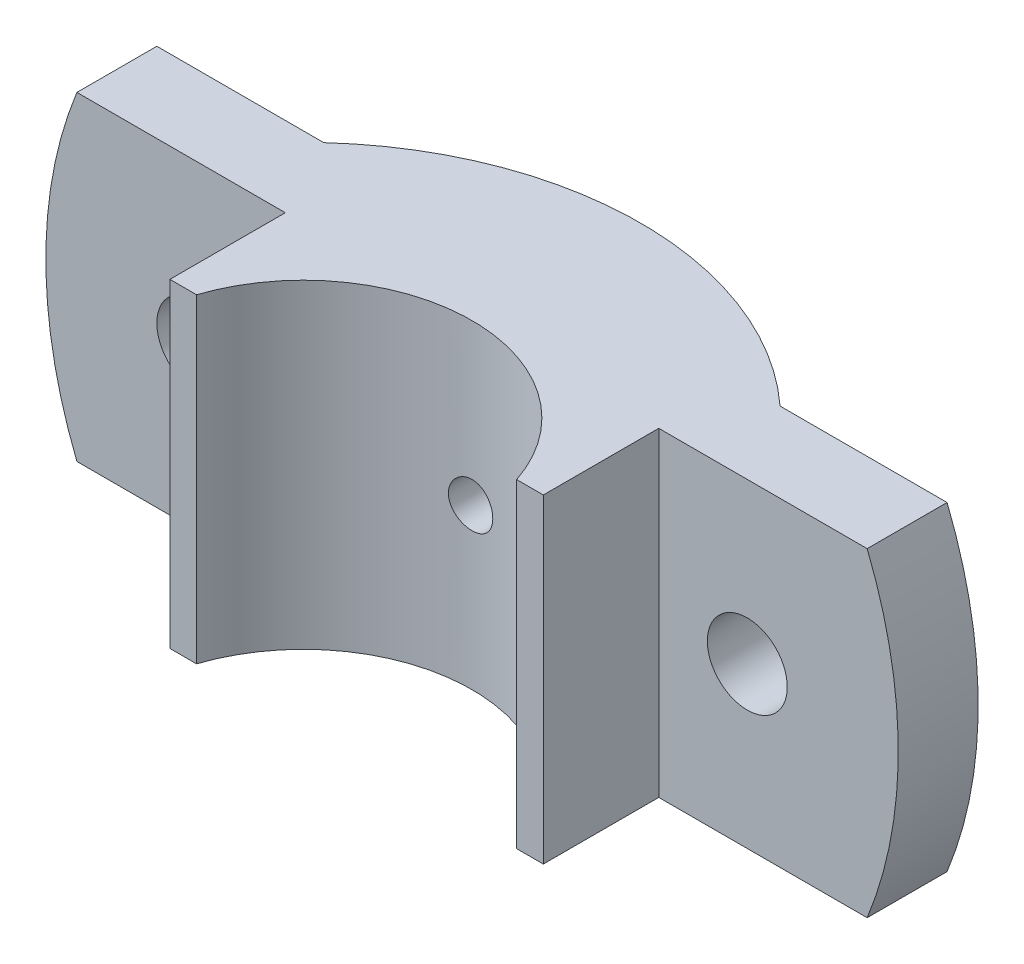
from build123d import *

# Parameters (mm, degrees)
BOSS_EXTRUDE1_DEPTH = 18
CUT_EXTRUDE1_DEPTH  = 36
SKETCH7_R           = 4.5
CUT_EXTRUDE3_DEPTH  = 36
CUT_EXTRUDE4_DEPTH  = 11


with BuildPart() as part:
    # Sketch2 → Boss-Extrude1 (new body, symmetric)
    with BuildSketch(Plane(origin=(0, 0, 0), x_dir=(1, 0, 0), z_dir=(0, 1, 0))):
        with BuildLine():
            Line((-25.690465157, 28), (-50, 28))
            Line((-50, 28), (-50, 19))
            Line((-50, 19), (-21.027756377, 19))
            Line((-21.027756377, 19), (-21.027756377, 6))
            Line((-21.027756377, 6), (-18.027756377, 6))
            ThreePointArc((-18.027756377, 6), (0, 19), (18.027756377, 6))
            Line((18.027756377, 6), (21.027756377, 6))
            Line((21.027756377, 6), (21.027756377, 19))
            Line((21.027756377, 19), (50, 19))
            Line((50, 19), (50, 28))
            Line((50, 28), (25.690465157, 28))
            ThreePointArc((25.690465157, 28), (0, 38), (-25.690465157, 28))
        make_face()
    extrude(amount=BOSS_EXTRUDE1_DEPTH, both=True)

    # Sketch4 → Cut-Extrude1 (cut)
    with BuildSketch(Plane(origin=(0, 0, -28), x_dir=(-1, 0, 0), z_dir=(0, 0, -1))):
        with BuildLine():
            Line((-50, -18), (-44.497190923, -18))
            ThreePointArc((-44.497190923, -18), (-48, 0), (-44.497190923, 18))
            Line((-44.497190923, 18), (-50, 18))
            Line((-50, 18), (-50, -18))
        make_face()
    cut_extrude1 = extrude(amount=-CUT_EXTRUDE1_DEPTH, mode=Mode.SUBTRACT)

    # Mirror1: Cut-Extrude1 across plane
    add(cut_extrude1.mirror(Plane(origin=(0, 0, 0), x_dir=(0, 0, 1), z_dir=(1, 0, 0))), mode=Mode.SUBTRACT)

    # Sketch7 → Cut-Extrude3 (cut)
    with BuildSketch(Plane(origin=(0, 0, -28), x_dir=(-1, 0, 0), z_dir=(0, 0, -1))):
        with Locations((-31, 0)):
            Circle(SKETCH7_R)
    cut_extrude3 = extrude(amount=-CUT_EXTRUDE3_DEPTH, mode=Mode.SUBTRACT)

    # Sketch8 → Cut-Extrude4 (cut, through all)
    with BuildSketch(Plane(origin=(0, 0, -28), x_dir=(-1, 0, 0), z_dir=(0, 0, -1))):
        with BuildLine():
            Line((-25.690465157, 6.637683312), (-25.690465157, -6.637683312))
            ThreePointArc((-25.690465157, -6.637683312), (-22.5, 0), (-25.690465157, 6.637683312))
        make_face()
    cut_extrude4 = extrude(amount=CUT_EXTRUDE4_DEPTH, mode=Mode.SUBTRACT)

    # Mirror3: Cut-Extrude3, Cut-Extrude4 across plane
    add(cut_extrude3.mirror(Plane(origin=(0, 0, 0), x_dir=(0, 0, 1), z_dir=(1, 0, 0))), mode=Mode.SUBTRACT)
    add(cut_extrude4.mirror(Plane(origin=(0, 0, 0), x_dir=(0, 0, 1), z_dir=(1, 0, 0))), mode=Mode.SUBTRACT)

    # Sketch11 → CBORE for M5 Hex Head Bolt1 (revolve, cut)
    with BuildSketch(Plane(origin=(0, 0, -38), x_dir=(0, 1, 0), z_dir=(1, 0, 0))):
        Polygon((0, 0), (0, 32), (2.5, 32), (2.5, 13.300129879), (2.9995, 13), (3, 0), align=None)
    revolve(axis=Axis((0, 0, -44.35), (0, 0, 1)), mode=Mode.SUBTRACT)


solid = part.part
